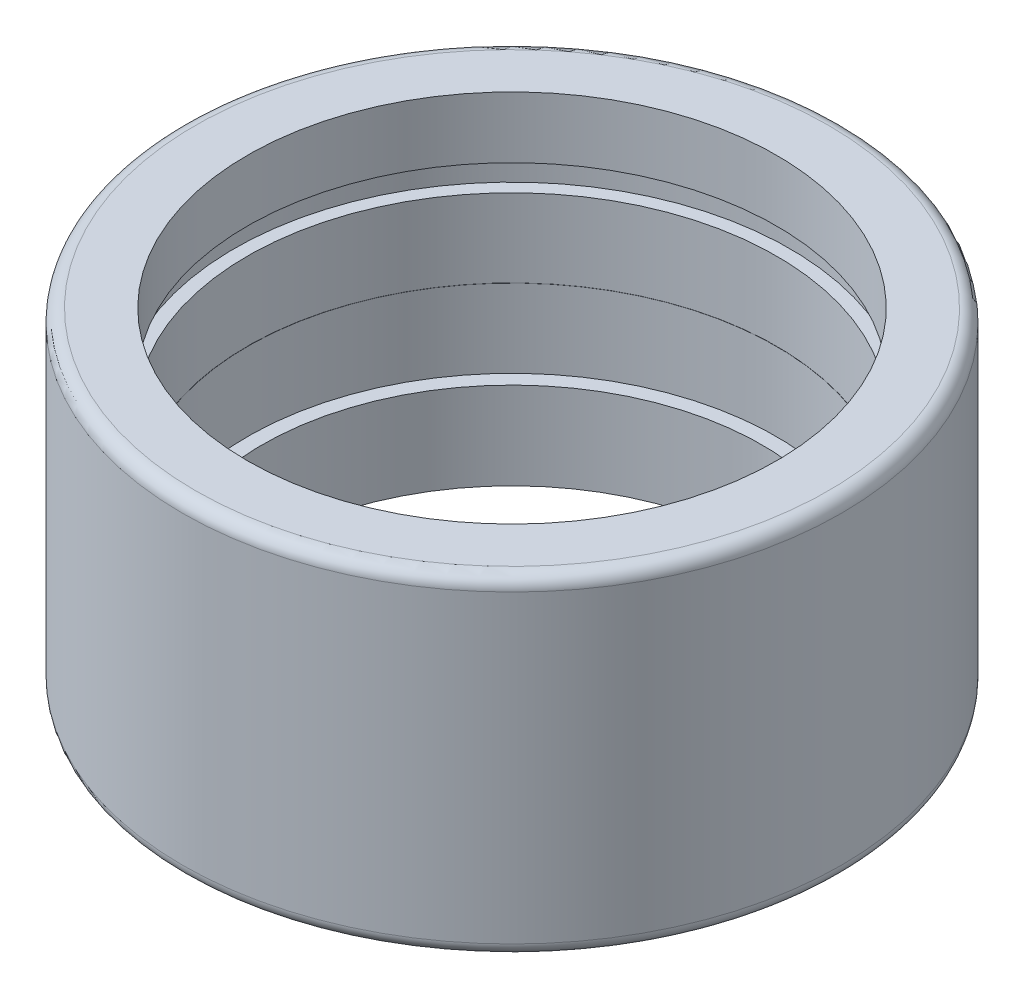
from build123d import *

# Parameters (mm, degrees)
SKETCH1_R               = 12.65
BOSS_EXTRUDE1_DEPTH     = 6.35
SKETCH2_R               = 9.6
CUT_EXTRUDE1_DEPTH      = 7.35
CUT_EXTRUDE1_DEPTH_BACK = 7.35
SKETCH3_R               = 10.15238
CUT_EXTRUDE2_DEPTH      = 3
SKETCH4_R               = 10.16
CUT_EXTRUDE3_DEPTH      = 10.826
SKETCH6_R               = 10.66038
CUT_EXTRUDE4_DEPTH      = 1
FILLET1_R               = 0.5


with BuildPart() as part:
    # Sketch1 → Boss-Extrude1 (new body, symmetric)
    with BuildSketch(Plane(origin=(0, 0, 0), x_dir=(1, 0, 0), z_dir=(0, 1, 0))):
        Circle(SKETCH1_R)
    extrude(amount=BOSS_EXTRUDE1_DEPTH, both=True)

    # Sketch2 → Cut-Extrude1 (cut, two sides)
    with BuildSketch(Plane(origin=(0, 0, 0), x_dir=(1, 0, 0), z_dir=(0, 1, 0))) as cut_extrude1_sk:
        Circle(SKETCH2_R)
    extrude(amount=CUT_EXTRUDE1_DEPTH, mode=Mode.SUBTRACT)
    extrude(cut_extrude1_sk.sketch, amount=-CUT_EXTRUDE1_DEPTH_BACK, mode=Mode.SUBTRACT)

    # Sketch3 → Cut-Extrude2 (cut, symmetric)
    with BuildSketch(Plane(origin=(0, 0, 0), x_dir=(1, 0, 0), z_dir=(0, 1, 0))):
        Circle(SKETCH3_R)
    extrude(amount=CUT_EXTRUDE2_DEPTH, both=True, mode=Mode.SUBTRACT)

    # Sketch4 → Cut-Extrude3 (cut)
    with BuildSketch(Plane(origin=(0, 0, 0), x_dir=(1, 0, 0), z_dir=(0, 1, 0))):
        Circle(SKETCH4_R)
    extrude(amount=CUT_EXTRUDE3_DEPTH, mode=Mode.SUBTRACT)

    # Sketch6 → Cut-Extrude4 (cut)
    with BuildSketch(Plane(origin=(0, 2.9972, 0), x_dir=(1, 0, 0), z_dir=(0, 1, 0))):
        Circle(SKETCH6_R)
    extrude(amount=CUT_EXTRUDE4_DEPTH, mode=Mode.SUBTRACT)

    # Fillet1
    fillet1_edges = [part.edges().sort_by_distance(p)[0] for p in [
        (-12.65, -6.35, 0),
        (-12.65, 6.35, 0),
    ]]
    fillet(fillet1_edges, radius=FILLET1_R)


solid = part.part
